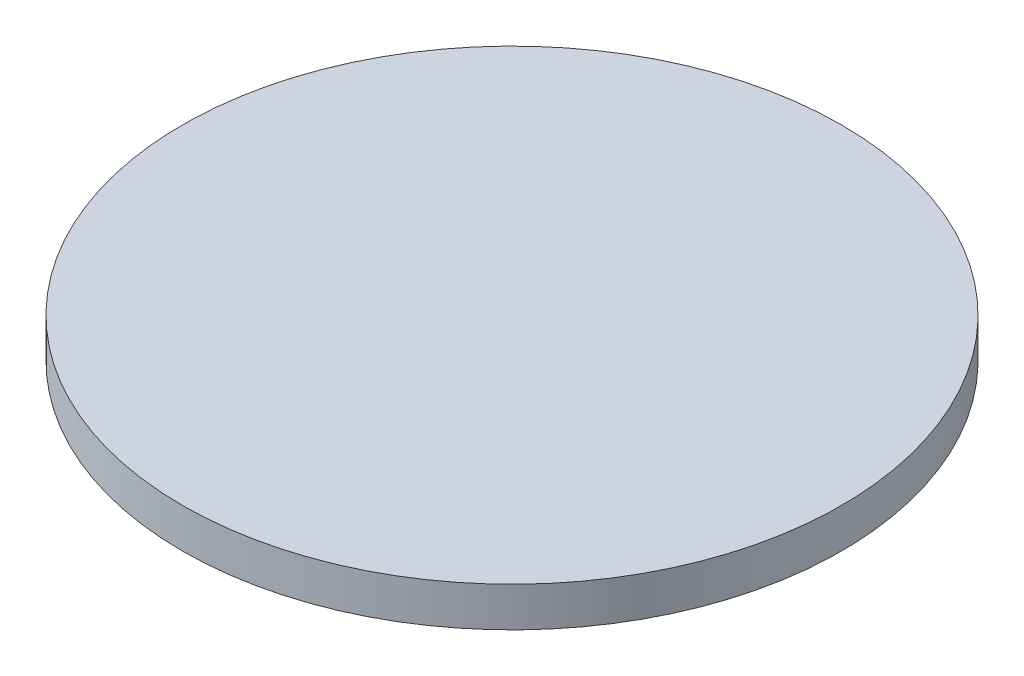
from build123d import *

# Parameters (mm, degrees)
SKETCH_1_R      = 25
EXTRUDE_1_DEPTH = 3


with BuildPart() as part:
    # 草图1 → 凸台-拉伸1 (new body)
    with BuildSketch(Plane(origin=(0, 0, 0), x_dir=(1, 0, 0), z_dir=(0, 1, 0))):
        with Locations(Location((0, 0, 0), (0, 0, 270))):  # turned: the seam where the file's is
            Circle(SKETCH_1_R)
    extrude(amount=EXTRUDE_1_DEPTH)


solid = part.part
